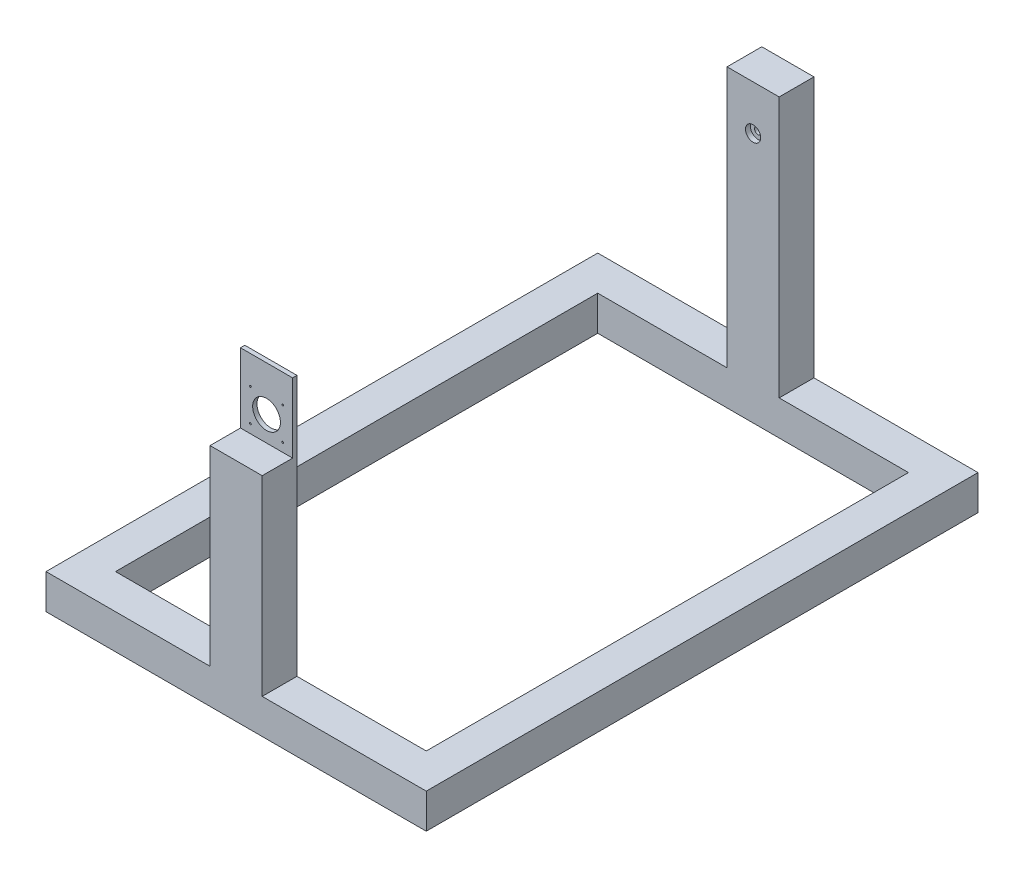
from build123d import *

# Parameters (mm, degrees)
SKETCH1_W           = 454.199999904
SKETCH1_H           = 704.848240034
BOSS_EXTRUDE1_DEPTH = 50.8
SKETCH2_W           = 76.2
SKETCH2_H           = 50.8
BOSS_EXTRUDE2_DEPTH = 279.4
SKETCH4_W           = 76.2
SKETCH4_H           = 50.8
BOSS_EXTRUDE3_DEPTH = 381
SKETCH5_W           = 76.2
SKETCH5_H           = 6.35
BOSS_EXTRUDE4_DEPTH = 101.6
SKETCH6_R           = 1.27
SKETCH6_R_2         = 20.32
CUT_EXTRUDE2_DEPTH  = 6.35
SKETCH8_R           = 11.1125
CUT_EXTRUDE4_DEPTH  = 7.14375
SKETCH9_R           = 5.08
CUT_EXTRUDE5_DEPTH  = 50.8


with BuildPart() as part:
    # Sketch1 → Boss-Extrude1 (new body)
    with BuildSketch(Plane(origin=(0, 0, 0), x_dir=(1, 0, 0), z_dir=(0, 1, 0))):
        Polygon((-277.899999952, 25.4), (277.899999952, 25.4), (277.899999952, -25.4), (277.899999952, -781.048240034), (227.099999952, -781.048240034), (-227.099999952, -781.048240034), (-277.899999952, -781.048240034), (-277.899999952, -25.4), align=None)
        with Locations((0, -377.824120017)):
            Rectangle(SKETCH1_W, SKETCH1_H, mode=Mode.SUBTRACT)
    extrude(amount=BOSS_EXTRUDE1_DEPTH)

    # Sketch2 → Boss-Extrude2 (add)
    with BuildSketch(Plane(origin=(0, 50.8, 0), x_dir=(1, 0, 0), z_dir=(0, 1, 0))):
        with Locations((0, -755.648240034)):
            Rectangle(SKETCH2_W, SKETCH2_H)
    extrude(amount=BOSS_EXTRUDE2_DEPTH)

    # Sketch4 → Boss-Extrude3 (add)
    with BuildSketch(Plane(origin=(0, 50.8, 0), x_dir=(1, 0, 0), z_dir=(0, 1, 0))):
        Rectangle(SKETCH4_W, SKETCH4_H)
    extrude(amount=BOSS_EXTRUDE3_DEPTH)

    # Sketch5 → Boss-Extrude4 (add)
    with BuildSketch(Plane(origin=(0, 330.2, 0), x_dir=(1, 0, 0), z_dir=(0, 1, 0))):
        with Locations((0, -733.423240034)):
            Rectangle(SKETCH5_W, SKETCH5_H)
    extrude(amount=BOSS_EXTRUDE4_DEPTH)

    # Sketch6 → Cut-Extrude2 (cut)
    with BuildSketch(Plane.XY.offset(736.598240034)):
        with Locations((-23.57317231, 390.04634462)):
            Circle(SKETCH6_R)
        with Locations((-23.57317231, 342.9)):
            Circle(SKETCH6_R)
        with Locations((23.57317231, 390.04634462)):
            Circle(SKETCH6_R)
        with Locations((23.57317231, 342.9)):
            Circle(SKETCH6_R)
        with Locations((0, 366.47317231)):
            Circle(SKETCH6_R_2)
    extrude(amount=-CUT_EXTRUDE2_DEPTH, mode=Mode.SUBTRACT)

    # Sketch8 → Cut-Extrude4 (cut)
    with BuildSketch(Plane.XY.offset(25.4)):
        with Locations((0, 366.47317231)):
            Circle(SKETCH8_R)
    extrude(amount=-CUT_EXTRUDE4_DEPTH, mode=Mode.SUBTRACT)

    # Sketch9 → Cut-Extrude5 (cut)
    with BuildSketch(Plane.XY.offset(18.25625)):
        with Locations((0, 366.47317231)):
            Circle(SKETCH9_R)
    extrude(amount=-CUT_EXTRUDE5_DEPTH, mode=Mode.SUBTRACT)


solid = part.part
